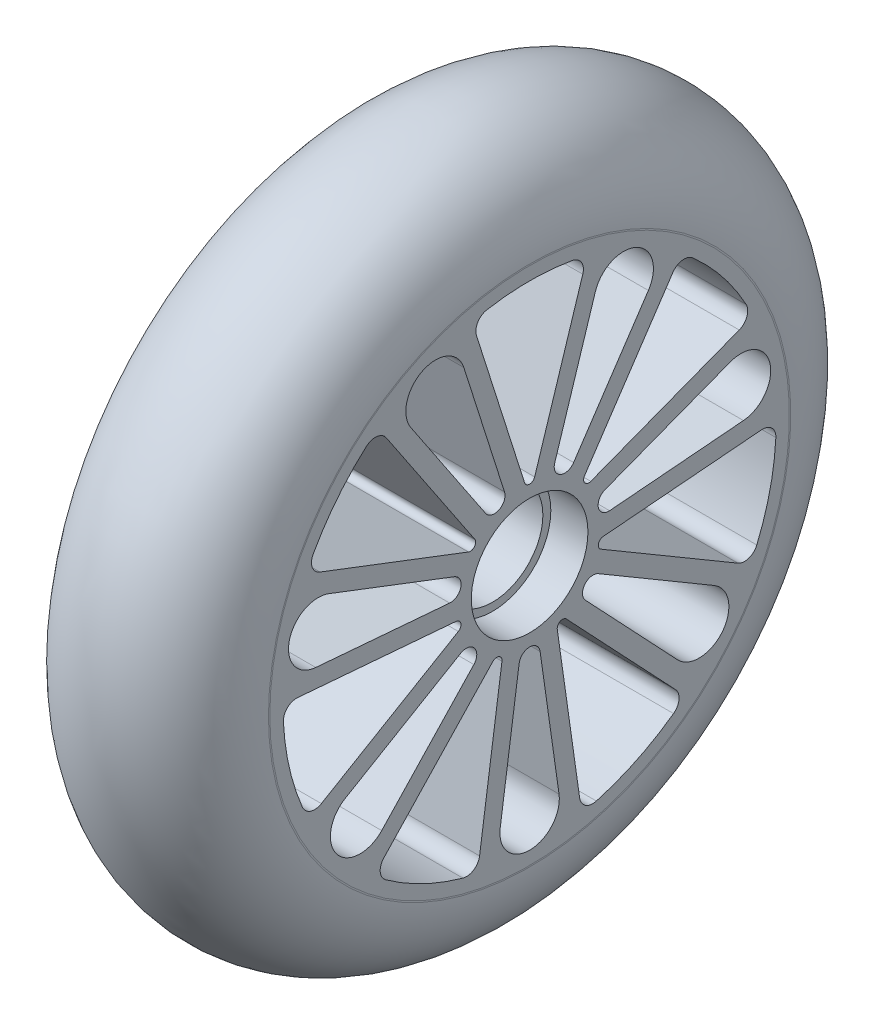
from build123d import *

# Parameters (mm, degrees)
SKETCH5_R               = 11
CUT_EXTRUDE1_DEPTH      = 7
SKETCH6_R               = 9.5
CUT_EXTRUDE2_DEPTH      = 8
CUT_EXTRUDE2_DEPTH_BACK = 28.879225258
CUT_EXTRUDE3_DEPTH      = 1
CUT_EXTRUDE3_DEPTH_BACK = 35.879225258


with BuildPart() as part:
    # Sketch2 → Revolve1 (revolve)
    with BuildSketch(Plane.XY):
        with BuildLine():
            Line((-14.019353848, 46.058143157), (14.019353848, 46.058143157))
            ThreePointArc((14.019353848, 46.058143157), (15.183914743, 48.1633599), (17.439612629, 49))
            Line((17.439612629, 49), (17.437695742, 49.258564993))
            ThreePointArc((17.437695742, 49.258564993), (-0.129286049, 66.439133401), (-17.439612629, 49))
            ThreePointArc((-17.439612629, 49), (-15.183914743, 48.1633599), (-14.019353848, 46.058143157))
        make_face()
    revolve(axis=Axis((-19.645151391, 0, 0), (1, 0, 0)))

    # Sketch4 → Revolve2 (revolve)
    with BuildSketch(Plane.XY):
        with BuildLine():
            Line((-14.019353848, 46.058143157), (14.019353848, 46.058143157))
            ThreePointArc((14.019353848, 46.058143157), (15.183914743, 48.1633599), (17.439612629, 49))
            Line((17.439612629, 49), (17.439612629, 0))
            Line((17.439612629, 0), (-17.439612629, 0))
            Line((-17.439612629, 0), (-17.439612629, 49))
            ThreePointArc((-17.439612629, 49), (-15.183914743, 48.1633599), (-14.019353848, 46.058143157))
        make_face()
    revolve(axis=Axis((-17.439612629, 0, 0), (1, 0, 0)))

    # Sketch5 → Cut-Extrude1 (cut)
    with BuildSketch(Plane(origin=(17.439612629, 0, 0), x_dir=(0, 0, -1), z_dir=(1, 0, 0))):
        Circle(SKETCH5_R)
    cut_extrude1 = extrude(amount=-CUT_EXTRUDE1_DEPTH, mode=Mode.SUBTRACT)

    # Mirror1: Cut-Extrude1 across plane
    add(cut_extrude1.mirror(Plane(origin=(0, 0, 0), x_dir=(0, 0, 1), z_dir=(1, 0, 0))), mode=Mode.SUBTRACT)

    # Sketch6 → Cut-Extrude2 (cut, two sides)
    with BuildSketch(Plane(origin=(10.439612629, 0, 0), x_dir=(0, 0, -1), z_dir=(1, 0, 0))) as cut_extrude2_sk:
        Circle(SKETCH6_R)
    extrude(amount=CUT_EXTRUDE2_DEPTH, mode=Mode.SUBTRACT)
    extrude(cut_extrude2_sk.sketch, amount=-CUT_EXTRUDE2_DEPTH_BACK, mode=Mode.SUBTRACT)

    # Sketch7 → Cut-Extrude3 (cut, two sides)
    with BuildSketch(Plane(origin=(17.439612629, 0, 0), x_dir=(0, 0, -1), z_dir=(1, 0, 0))) as cut_extrude3_sk:
        with BuildLine():
            Line((0.953103894, 14.00157653), (10.025977251, 42.574457114))
            ThreePointArc((10.025977251, 42.574457114), (9.781854194, 44.625759604), (8.07749124, 45.793057719))
            ThreePointArc((8.07749124, 45.793057719), (0, 46.5), (-8.07749124, 45.793057719))
            ThreePointArc((-8.07749124, 45.793057719), (-9.781854194, 44.625759604), (-10.025977251, 42.574457114))
            Line((-10.025977251, 42.574457114), (-0.953103894, 14.00157653))
            ThreePointArc((-0.953103894, 14.00157653), (0, 13.304219832), (0.953103894, 14.00157653))
        make_face()
        with BuildLine():
            Line((10.352622778, 9.475006807), (27.034956351, 34.383364488))
            ThreePointArc((27.034956351, 34.383364488), (28.790937454, 35.471467579), (30.766220791, 34.866741434))
            ThreePointArc((30.766220791, 34.866741434), (36.355163935, 28.992275786), (40.838687616, 22.236267533))
            ThreePointArc((40.838687616, 22.236267533), (40.988710121, 20.175944447), (39.53714549, 18.706115173))
            Line((39.53714549, 18.706115173), (11.541123893, 7.984673547))
            ThreePointArc((11.541123893, 7.984673547), (10.401657915, 8.295045387), (10.352622778, 9.475006807))
        make_face()
        with BuildLine():
            Line((13.862613343, -2.186436297), (43.738016408, 0.300897109))
            ThreePointArc((43.738016408, 0.300897109), (45.683565971, -0.393563019), (46.442341049, -2.314942302))
            ThreePointArc((46.442341049, -2.314942302), (45.334147916, -10.347223429), (42.84751926, -18.064885642))
            ThreePointArc((42.84751926, -18.064885642), (41.330231309, -19.466768393), (39.276036765, -19.248313029))
            Line((39.276036765, -19.248313029), (13.438442206, -4.044851475))
            ThreePointArc((13.438442206, -4.044851475), (12.970655264, -2.960467423), (13.862613343, -2.186436297))
        make_face()
        with BuildLine():
            Line((6.933773315, -12.201448274), (27.505458017, -34.00815193))
            ThreePointArc((27.505458017, -34.00815193), (28.175537537, -35.962232636), (27.146431247, -37.753427269))
            ThreePointArc((27.146431247, -37.753427269), (20.175593869, -41.895052357), (12.591294971, -44.762811473))
            ThreePointArc((12.591294971, -44.762811473), (10.549245338, -44.450607583), (9.43927127, -42.708368926))
            Line((9.43927127, -42.708368926), (5.216339443, -13.028520837))
            ThreePointArc((5.216339443, -13.028520837), (5.772484647, -11.986687881), (6.933773315, -12.201448274))
        make_face()
        with BuildLine():
            Line((-5.216339443, -13.028520837), (-9.43927127, -42.708368926))
            ThreePointArc((-9.43927127, -42.708368926), (-10.549245338, -44.450607583), (-12.591294971, -44.762811473))
            ThreePointArc((-12.591294971, -44.762811473), (-20.175593869, -41.895052357), (-27.146431247, -37.753427269))
            ThreePointArc((-27.146431247, -37.753427269), (-28.175537537, -35.962232636), (-27.505458017, -34.00815193))
            Line((-27.505458017, -34.00815193), (-6.933773315, -12.201448274))
            ThreePointArc((-6.933773315, -12.201448274), (-5.772484647, -11.986687881), (-5.216339443, -13.028520837))
        make_face()
        with BuildLine():
            Line((-13.438442206, -4.044851475), (-39.276036765, -19.248313029))
            ThreePointArc((-39.276036765, -19.248313029), (-41.330231309, -19.466768393), (-42.84751926, -18.064885642))
            ThreePointArc((-42.84751926, -18.064885642), (-45.334147916, -10.347223429), (-46.442341049, -2.314942302))
            ThreePointArc((-46.442341049, -2.314942302), (-45.683565971, -0.393563019), (-43.738016408, 0.300897109))
            Line((-43.738016408, 0.300897109), (-13.862613343, -2.186436297))
            ThreePointArc((-13.862613343, -2.186436297), (-12.970655264, -2.960467423), (-13.438442206, -4.044851475))
        make_face()
        with BuildLine():
            Line((-11.541123893, 7.984673547), (-39.53714549, 18.706115173))
            ThreePointArc((-39.53714549, 18.706115173), (-40.988710121, 20.175944447), (-40.838687616, 22.236267533))
            ThreePointArc((-40.838687616, 22.236267533), (-36.355163935, 28.992275786), (-30.766220791, 34.866741434))
            ThreePointArc((-30.766220791, 34.866741434), (-28.790937454, 35.471467579), (-27.034956351, 34.383364488))
            Line((-27.034956351, 34.383364488), (-10.352622778, 9.475006807))
            ThreePointArc((-10.352622778, 9.475006807), (-10.401657915, 8.295045387), (-11.541123893, 7.984673547))
        make_face()
        with BuildLine():
            Line((4.734554138, 14.392730444), (12.402770228, 38.541973357))
            ThreePointArc((12.402770228, 38.541973357), (20.175593869, 41.895052357), (22.400327415, 33.727403566))
            Line((22.400327415, 33.727403566), (8.300743558, 12.675344134))
            ThreePointArc((8.300743558, 12.675344134), (5.772484647, 11.986687881), (4.734554138, 14.392730444))
        make_face()
        with BuildLine():
            Line((14.204636001, 5.272097172), (37.866328919, 14.333651097))
            ThreePointArc((37.866328919, 14.333651097), (45.334147916, 10.347223429), (40.335521631, 3.515410976))
            Line((40.335521631, 3.515410976), (15.085412051, 1.413165161))
            ThreePointArc((15.085412051, 1.413165161), (12.970655264, 2.960467423), (14.204636001, 5.272097172))
        make_face()
        with BuildLine():
            Line((12.978337234, -7.818532802), (34.815769602, -20.668202792))
            ThreePointArc((34.815769602, -20.668202792), (36.355163935, -28.992275786), (27.897245365, -29.34375778))
            Line((27.897245365, -29.34375778), (10.510457583, -10.913156002))
            ThreePointArc((10.510457583, -10.913156002), (10.401657915, -8.295045387), (12.978337234, -7.818532802))
        make_face()
        with BuildLine():
            Line((1.979085819, -15.021648107), (5.548225662, -40.106478424))
            ThreePointArc((5.548225662, -40.106478424), (0, -46.5), (-5.548225662, -40.106478424))
            Line((-5.548225662, -40.106478424), (-1.979085819, -15.021648107))
            ThreePointArc((-1.979085819, -15.021648107), (0, -13.304219832), (1.979085819, -15.021648107))
        make_face()
        with BuildLine():
            Line((-10.510457583, -10.913156002), (-27.897245365, -29.34375778))
            ThreePointArc((-27.897245365, -29.34375778), (-36.355163935, -28.992275786), (-34.815769602, -20.668202792))
            Line((-34.815769602, -20.668202792), (-12.978337234, -7.818532802))
            ThreePointArc((-12.978337234, -7.818532802), (-10.401657915, -8.295045387), (-10.510457583, -10.913156002))
        make_face()
        with BuildLine():
            Line((-15.085412051, 1.413165161), (-40.335521631, 3.515410976))
            ThreePointArc((-40.335521631, 3.515410976), (-45.334147916, 10.347223429), (-37.866328919, 14.333651097))
            Line((-37.866328919, 14.333651097), (-14.204636001, 5.272097172))
            ThreePointArc((-14.204636001, 5.272097172), (-12.970655264, 2.960467423), (-15.085412051, 1.413165161))
        make_face()
        with BuildLine():
            Line((-8.300743558, 12.675344134), (-22.400327415, 33.727403566))
            ThreePointArc((-22.400327415, 33.727403566), (-20.175593869, 41.895052357), (-12.402770228, 38.541973357))
            Line((-12.402770228, 38.541973357), (-4.734554138, 14.392730444))
            ThreePointArc((-4.734554138, 14.392730444), (-5.772484647, 11.986687881), (-8.300743558, 12.675344134))
        make_face()
    extrude(amount=CUT_EXTRUDE3_DEPTH, mode=Mode.SUBTRACT)
    extrude(cut_extrude3_sk.sketch, amount=-CUT_EXTRUDE3_DEPTH_BACK, mode=Mode.SUBTRACT)


solid = part.part
